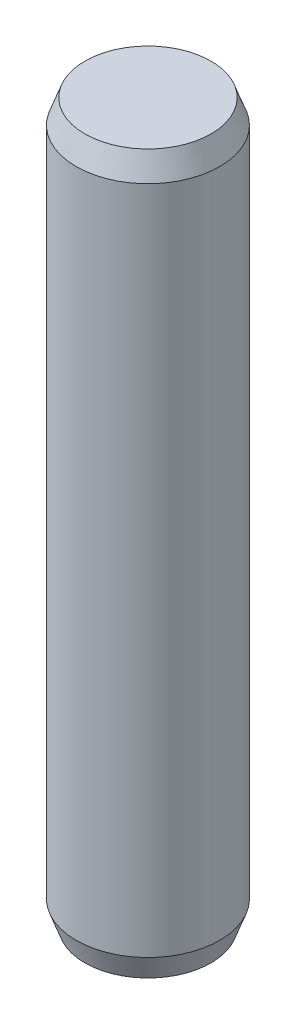
from build123d import *

# Parameters (mm, degrees)
SKETCH1_R           = 3
BOSS_EXTRUDE1_DEPTH = 30
CHAMFER1_SIZE       = 1
CHAMFER1_SIZE2      = 0.363970234
CHAMFER2_SIZE       = 1
CHAMFER2_SIZE2      = 0.363970234


with BuildPart() as part:
    # Sketch1 → Boss-Extrude1 (new body)
    with BuildSketch(Plane(origin=(0, 0, 0), x_dir=(1, 0, 0), z_dir=(0, 1, 0))):
        Circle(SKETCH1_R)
    extrude(amount=BOSS_EXTRUDE1_DEPTH)

    # Chamfer1
    chamfer1_edges = [part.edges().sort_by_distance(p)[0] for p in [
        (-3, 30, 0),
    ]]
    chamfer1_side = [part.faces().sort_by_distance(p)[0] for p in [
        (-3, 15, 0),
    ]]
    chamfer(chamfer1_edges, length=CHAMFER1_SIZE, length2=CHAMFER1_SIZE2, reference=chamfer1_side[0])

    # Chamfer2
    chamfer2_edges = [part.edges().sort_by_distance(p)[0] for p in [
        (-3, 0, 0),
    ]]
    chamfer2_side = [part.faces().sort_by_distance(p)[0] for p in [
        (-3, 14.5, 0),
    ]]
    chamfer(chamfer2_edges, length=CHAMFER2_SIZE, length2=CHAMFER2_SIZE2, reference=chamfer2_side[0])


solid = part.part
